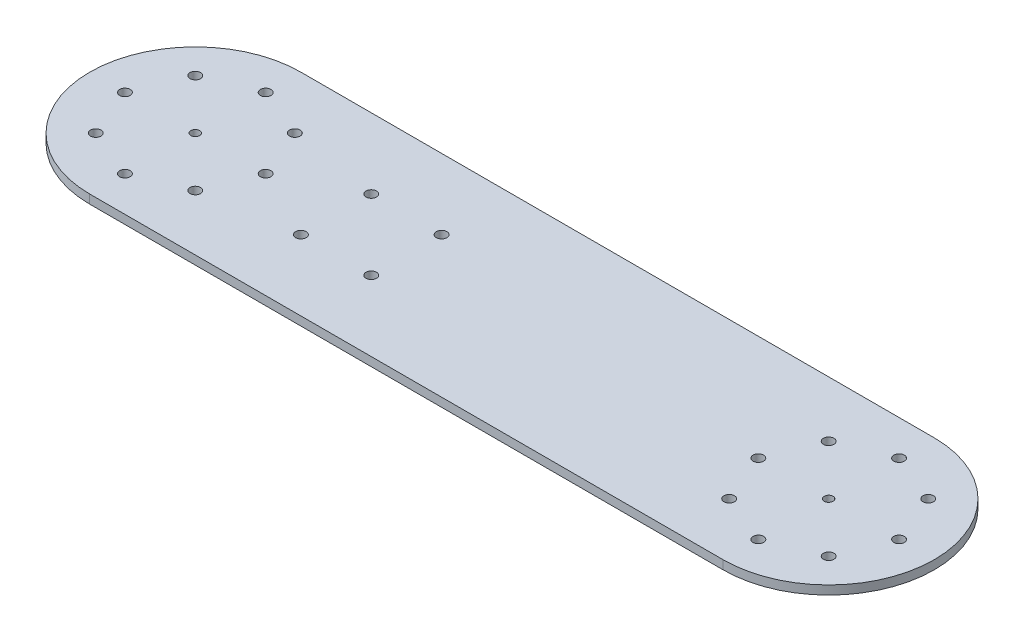
from build123d import *

# Parameters (mm, degrees)
SKETCH1_R           = 3.175
SKETCH1_R_2         = 3.81
BOSS_EXTRUDE1_DEPTH = 3.175


with BuildPart() as part:
    # Sketch1 → Boss-Extrude1 (new body, symmetric)
    with BuildSketch(Plane(origin=(0, 0, 0), x_dir=(1, 0, 0), z_dir=(0, 1, 0))):
        with BuildLine():
            Line((-228.6, 76.2), (228.6, 76.2))
            ThreePointArc((228.6, 76.2), (304.8, 0), (228.6, -76.2))
            Line((228.6, -76.2), (-228.6, -76.2))
            ThreePointArc((-228.6, -76.2), (-304.8, 0), (-228.6, 76.2))
        make_face()
        with Locations((-228.6, 0)):
            Circle(SKETCH1_R, mode=Mode.SUBTRACT)
        with Locations((-228.6, 50.8)):
            Circle(SKETCH1_R_2, mode=Mode.SUBTRACT)
        with Locations((-192.678975516, 35.921024484)):
            Circle(SKETCH1_R_2, mode=Mode.SUBTRACT)
        with Locations((-177.8, 0)):
            Circle(SKETCH1_R_2, mode=Mode.SUBTRACT)
        with Locations((-192.678975516, -35.921024484)):
            Circle(SKETCH1_R_2, mode=Mode.SUBTRACT)
        with Locations((-228.6, -50.8)):
            Circle(SKETCH1_R_2, mode=Mode.SUBTRACT)
        with Locations((-264.521024484, -35.921024484)):
            Circle(SKETCH1_R_2, mode=Mode.SUBTRACT)
        with Locations((-279.4, 0)):
            Circle(SKETCH1_R_2, mode=Mode.SUBTRACT)
        with Locations((-264.521024484, 35.921024484)):
            Circle(SKETCH1_R_2, mode=Mode.SUBTRACT)
        with Locations((228.6, 0)):
            Circle(SKETCH1_R, mode=Mode.SUBTRACT)
        with Locations((279.4, 0)):
            Circle(SKETCH1_R_2, mode=Mode.SUBTRACT)
        with Locations((264.521024484, -35.921024484)):
            Circle(SKETCH1_R_2, mode=Mode.SUBTRACT)
        with Locations((228.6, -50.8)):
            Circle(SKETCH1_R_2, mode=Mode.SUBTRACT)
        with Locations((192.678975516, -35.921024484)):
            Circle(SKETCH1_R_2, mode=Mode.SUBTRACT)
        with Locations((177.8, 0)):
            Circle(SKETCH1_R_2, mode=Mode.SUBTRACT)
        with Locations((192.678975516, 35.921024484)):
            Circle(SKETCH1_R_2, mode=Mode.SUBTRACT)
        with Locations((228.6, 50.8)):
            Circle(SKETCH1_R_2, mode=Mode.SUBTRACT)
        with Locations((264.521024484, 35.921024484)):
            Circle(SKETCH1_R_2, mode=Mode.SUBTRACT)
        with Locations((-127, 25.4)):
            Circle(SKETCH1_R_2, mode=Mode.SUBTRACT)
        with Locations((-76.2, -25.4)):
            Circle(SKETCH1_R_2, mode=Mode.SUBTRACT)
        with Locations((-127, -25.4)):
            Circle(SKETCH1_R_2, mode=Mode.SUBTRACT)
        with Locations((-76.2, 25.4)):
            Circle(SKETCH1_R_2, mode=Mode.SUBTRACT)
    extrude(amount=BOSS_EXTRUDE1_DEPTH, both=True)


solid = part.part
